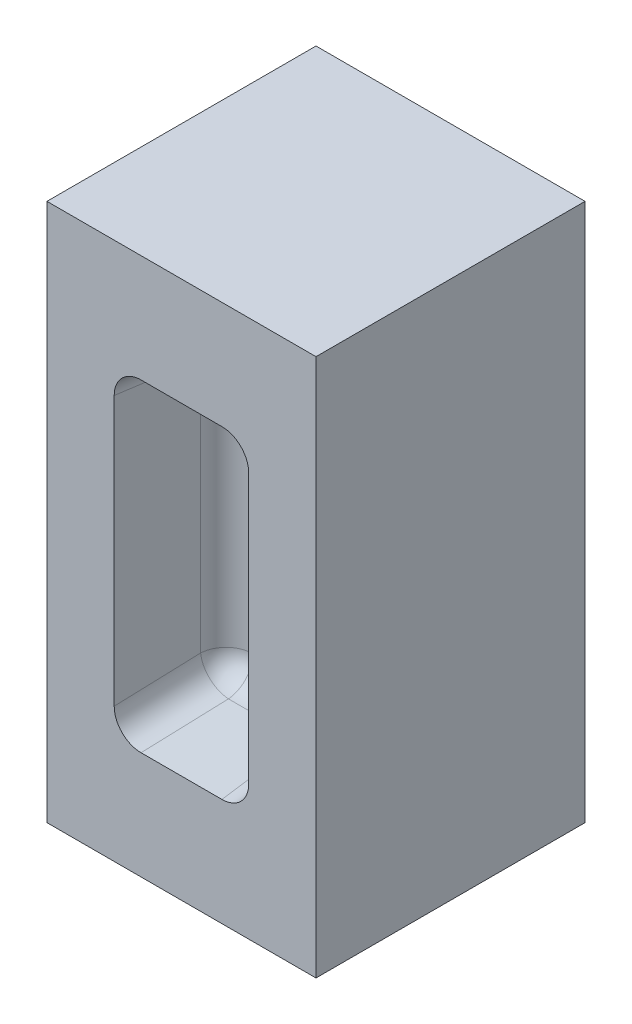
from build123d import *

# Parameters (mm, degrees)
SKIZZE1_W                       = 50
SKIZZE1_H                       = 100
AUFSATZ_LINEAR_AUSTRAGEN1_DEPTH = 50
SKIZZE2_W                       = 25
SKIZZE2_H                       = 60
SCHNITT_LINEAR_AUSTRAGEN1_DEPTH = 20
FORMSCHR_GE1_ANGLE              = 3
FORMSCHR_GE2_ANGLE              = 5
VERRUNDUNG1_R                   = 5


with BuildPart() as part:
    # Skizze1 → Aufsatz-Linear austragen1 (new body)
    with BuildSketch(Plane.XY):
        with Locations((25, 50)):
            Rectangle(SKIZZE1_W, SKIZZE1_H)
    extrude(amount=AUFSATZ_LINEAR_AUSTRAGEN1_DEPTH)

    # Skizze2 → Schnitt-Linear austragen1 (cut)
    with BuildSketch(Plane.XY.offset(50)):
        with Locations((25, 50)):
            Rectangle(SKIZZE2_W, SKIZZE2_H)
    extrude(amount=-SCHNITT_LINEAR_AUSTRAGEN1_DEPTH, mode=Mode.SUBTRACT)

    # Formschräge1
    formschr_ge1_faces = [part.faces().sort_by_distance(p)[0] for p in [
        (37.5, 50, 40),
        (12.5, 50, 40),
    ]]
    draft(formschr_ge1_faces, Plane.XY.offset(50), FORMSCHR_GE1_ANGLE)

    # Formschräge2
    formschr_ge2_faces = [part.faces().sort_by_distance(p)[0] for p in [
        (25, 20, 40.14586985),
        (25, 80, 40.14586985),
    ]]
    draft(formschr_ge2_faces, Plane.XY.offset(50), FORMSCHR_GE2_ANGLE)

    # Verrundung1
    verrundung1_edges = [part.edges().sort_by_distance(p)[0] for p in [
        (13.548155586, 50, 30),
        (13.024077793, 20.874886635, 40),
        (25, 78.250226729, 30),
        (13.024077793, 79.125113365, 40),
        (36.451844414, 50, 30),
        (36.975922207, 79.125113365, 40),
        (25, 21.749773271, 30),
        (36.975922207, 20.874886635, 40),
    ]]
    fillet(verrundung1_edges, radius=VERRUNDUNG1_R)


solid = part.part
